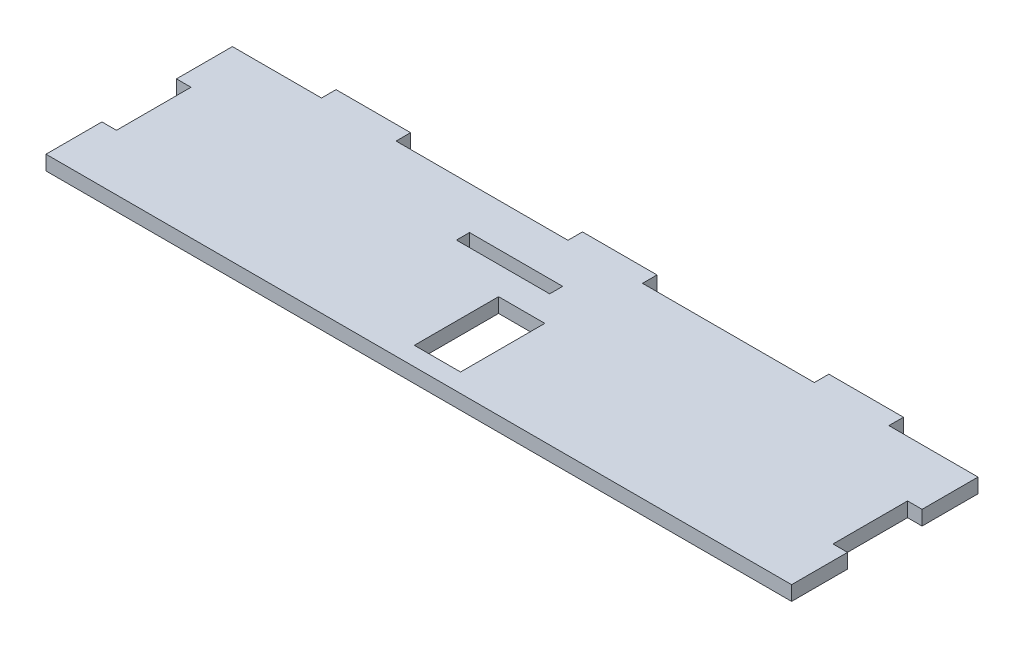
from build123d import *

# Parameters (mm, degrees)
SKETCH1_W           = 25
SKETCH1_H           = 3.5
BOSS_EXTRUDE1_DEPTH = 3.9
SKETCH1_3_W         = 12.4
SKETCH1_3_H         = 22.6
CUT_EXTRUDE3_DEPTH  = 105.165349325


with BuildPart() as part:
    # Sketch1 → Boss-Extrude1 (new body)
    with BuildSketch(Plane(origin=(0, 0, 0), x_dir=(1, 0, 0), z_dir=(0, 1, 0))):
        Polygon((-76.1, 25), (-100, 25), (-100, 10), (-96.1, 10), (-96.1, -10), (-100, -10), (-100, -25), (100, -25), (100, -10), (96.1, -10), (96.1, 10), (100, 10), (100, 25), (76.1, 25), (76.1, 28.9), (56.1, 28.9), (56.1, 25), (10, 25), (10, 28.9), (-10, 28.9), (-10, 25), (-56.1, 25), (-56.1, 28.9), (-76.1, 28.9), align=None)
        with Locations((-12.5, 11.85)):
            Rectangle(SKETCH1_W, SKETCH1_H, mode=Mode.SUBTRACT)
    extrude(amount=BOSS_EXTRUDE1_DEPTH)

    # Sketch1_3 → Cut-Extrude3 (cut, through all)
    with BuildSketch(Plane(origin=(0, 0, 0), x_dir=(1, 0, 0), z_dir=(0, 1, 0))):
        with Locations((0, -8.7)):
            Rectangle(SKETCH1_3_W, SKETCH1_3_H)
    extrude(amount=CUT_EXTRUDE3_DEPTH, mode=Mode.SUBTRACT)


solid = part.part
